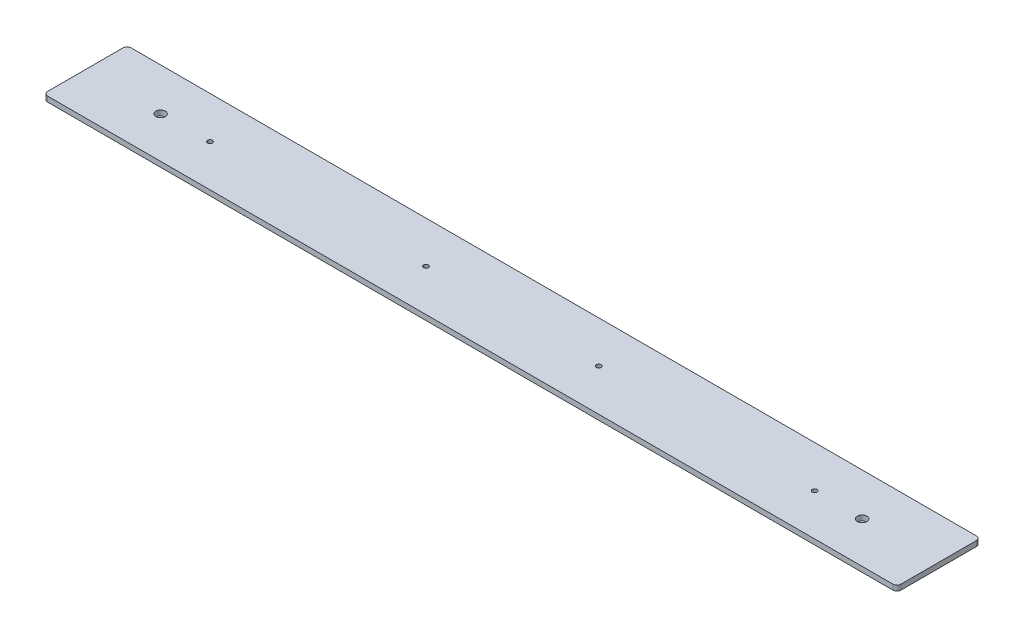
from build123d import *

# Parameters (mm, degrees)
SKETCH1_W                  = 519.1125
SKETCH1_H                  = 50.8
BOSS_EXTRUDE1_DEPTH        = 3.175
FILLET1_R                  = 2.54
F_4_CLEARANCE_HOLE1_D      = 2.9464
F_1_0_228_DIAMETER_HOLE1_D = 5.7912


with BuildPart() as part:
    # Sketch1 → Boss-Extrude1 (new body)
    with BuildSketch(Plane(origin=(0, 0, 0), x_dir=(1, 0, 0), z_dir=(0, 1, 0))):
        Rectangle(SKETCH1_W, SKETCH1_H)
    extrude(amount=BOSS_EXTRUDE1_DEPTH)

    # Fillet1
    fillet1_edges = [part.edges().sort_by_distance(p)[0] for p in [
        (259.55625, 1.5875, 25.4),
        (-259.55625, 1.5875, 25.4),
        (-259.55625, 1.5875, -25.4),
        (259.55625, 1.5875, -25.4),
    ]]
    fillet(fillet1_edges, radius=FILLET1_R)

    # #4 Clearance Hole1 (through all)
    with Locations(Plane(origin=(0, 3.175, 0), x_dir=(1, 0, 0), z_dir=(0, 1, 0))):
        with Locations((184.1103125, 0), (52.7446875, 0), (-52.3478125, 0), (-183.7134375, 0)):
            Hole(F_4_CLEARANCE_HOLE1_D / 2)

    # #1 (0.228) Diameter Hole1 (through all)
    with Locations(Plane(origin=(0, 3.175, 0), x_dir=(1, 0, 0), z_dir=(0, 1, 0))):
        with Locations((213.36, -0.3869309), (-213.36, -0.3869309)):
            Hole(F_1_0_228_DIAMETER_HOLE1_D / 2)


solid = part.part
